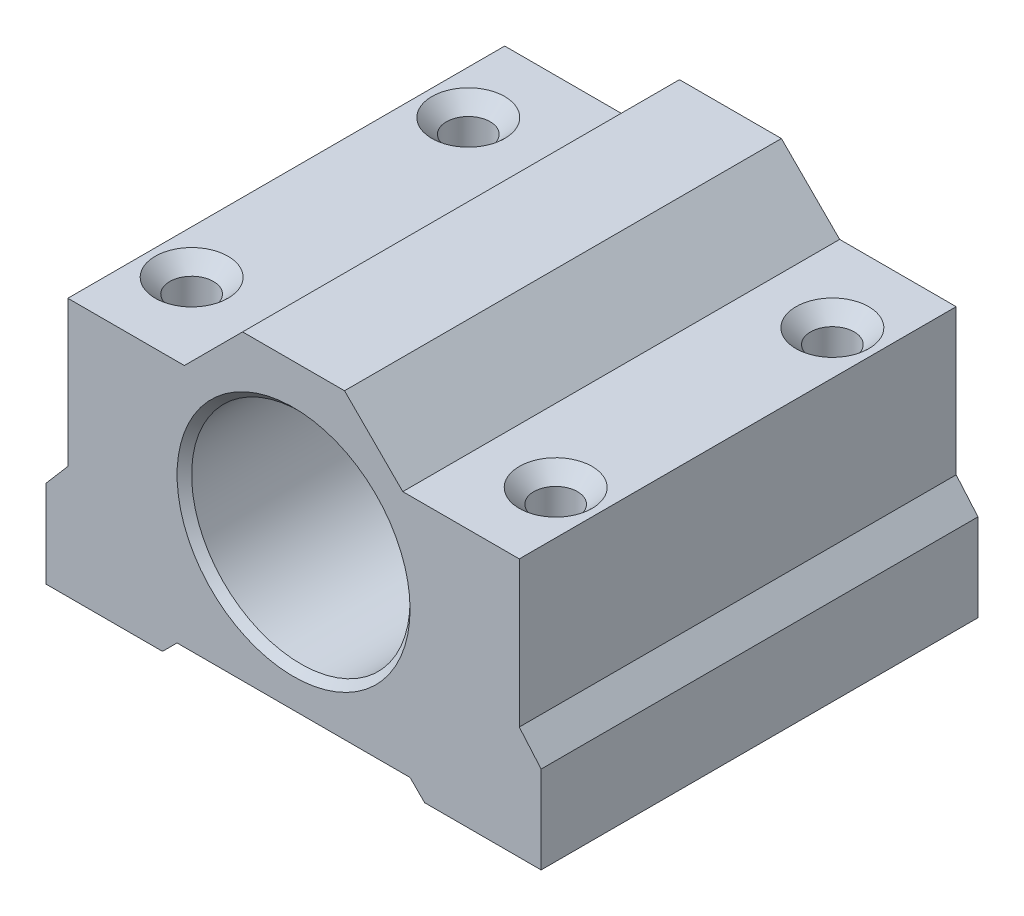
from build123d import *

# Parameters (mm, degrees)
BOSS_EXTRUDE1_DEPTH        = 30
M5_TAPPED_HOLE5_AT_2_COUNT = 2
M5_TAPPED_HOLE5_AT_2_PITCH = 19
M5_TAPPED_HOLE6_AT_2_COUNT = 2
M5_TAPPED_HOLE6_AT_2_PITCH = 19


with BuildPart() as part:
    # Sketch1 → Boss-Extrude1 (new body)
    with BuildSketch(Plane.XY):
        Polygon((0, 0), (0, 6), (1.5, 7.75), (1.5, 17.75), (9.5, 17.75), (13.5, 21.75), (20.5, 21.75), (24.5, 17.75), (32.5, 17.75), (32.5, 7.75), (34, 6), (34, 0), (26, 0), (25, 1), (9, 1), (8, 0), align=None)
    extrude(amount=BOSS_EXTRUDE1_DEPTH)

    # Sketch4 → CSK for M5 Countersunk Flat Head Screw1 (revolve, cut)
    with BuildSketch(Plane(origin=(17, 11, 30), x_dir=(0, -1, 0), z_dir=(1, 0, 0))):
        Polygon((0, 0), (0, 30), (7.75, 30), (7.5, 29.75), (7.5, 0.5), (8, 0), align=None)
    revolve(axis=Axis((17, 11, 36.35), (0, 0, -1)), mode=Mode.SUBTRACT)

    # Sketch19 → M5 Tapped Hole5 (revolve, cut)
    with BuildSketch(Plane(origin=(29.5, 0, 5.5), x_dir=(0, 0, -1), z_dir=(1, 0, 0))):
        Polygon((0, 0), (0, 17.75), (2.5, 17.75), (1.5, 16.75), (1.5, 1), (2.5, 0), align=None)
    m5_tapped_hole5 = revolve(axis=Axis((29.5, -6.35, 5.5), (0, 1, 0)), mode=Mode.SUBTRACT)

    # M5 Tapped Hole5 at 2: M5 Tapped Hole5 ×2
    with Locations(*[(0, 0, i * M5_TAPPED_HOLE5_AT_2_PITCH) for i in range(1, M5_TAPPED_HOLE5_AT_2_COUNT)]):
        add(m5_tapped_hole5, mode=Mode.SUBTRACT)

    # Sketch21 → M5 Tapped Hole6 (revolve, cut)
    with BuildSketch(Plane(origin=(4.5, 0, 5.5), x_dir=(0, 0, -1), z_dir=(1, 0, 0))):
        Polygon((0, 0), (0, 17.75), (2.5, 17.75), (1.5, 16.75), (1.5, 1), (2.5, 0), align=None)
    m5_tapped_hole6 = revolve(axis=Axis((4.5, -6.35, 5.5), (0, 1, 0)), mode=Mode.SUBTRACT)

    # M5 Tapped Hole6 at 2: M5 Tapped Hole6 ×2
    with Locations(*[(0, 0, i * M5_TAPPED_HOLE6_AT_2_PITCH) for i in range(1, M5_TAPPED_HOLE6_AT_2_COUNT)]):
        add(m5_tapped_hole6, mode=Mode.SUBTRACT)


solid = part.part
